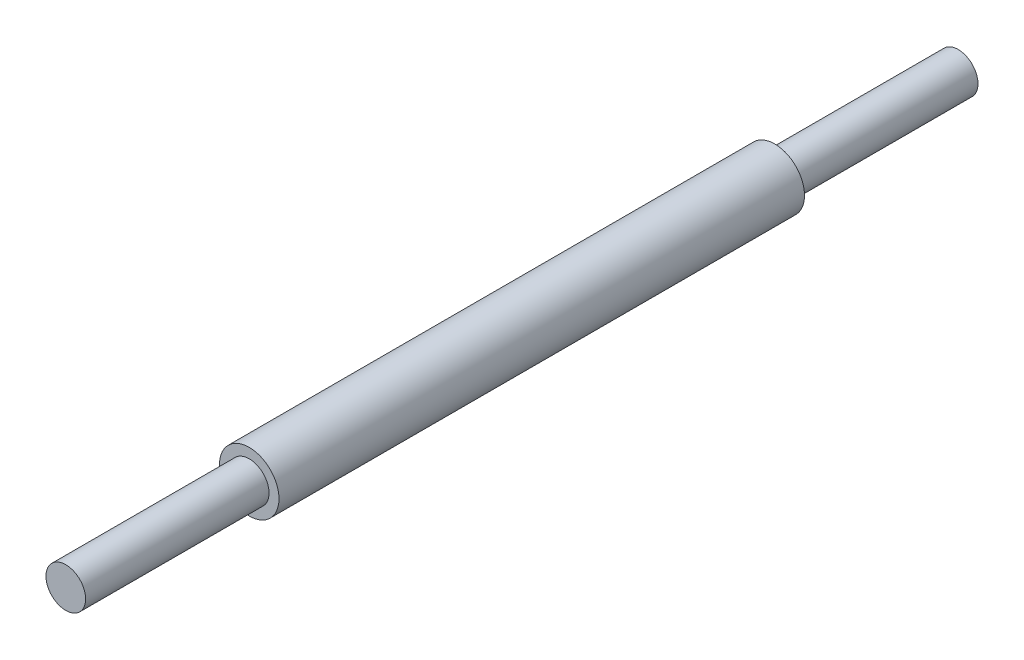
from build123d import *

# Parameters (mm, degrees)
SKETCH_1_R      = 1.5
EXTRUDE_1_DEPTH = 13.25
SKETCH_2_R      = 1
EXTRUDE_2_DEPTH = 22.5


with BuildPart() as part:
    # Эскиз1 → Бобышка-Вытянуть1 (new body, symmetric)
    with BuildSketch(Plane.XY):
        Circle(SKETCH_1_R)
    extrude(amount=EXTRUDE_1_DEPTH, both=True)

    # Эскиз2 → Бобышка-Вытянуть2 (add, symmetric)
    with BuildSketch(Plane.XY):
        Circle(SKETCH_2_R)
    extrude(amount=EXTRUDE_2_DEPTH, both=True)


solid = part.part
